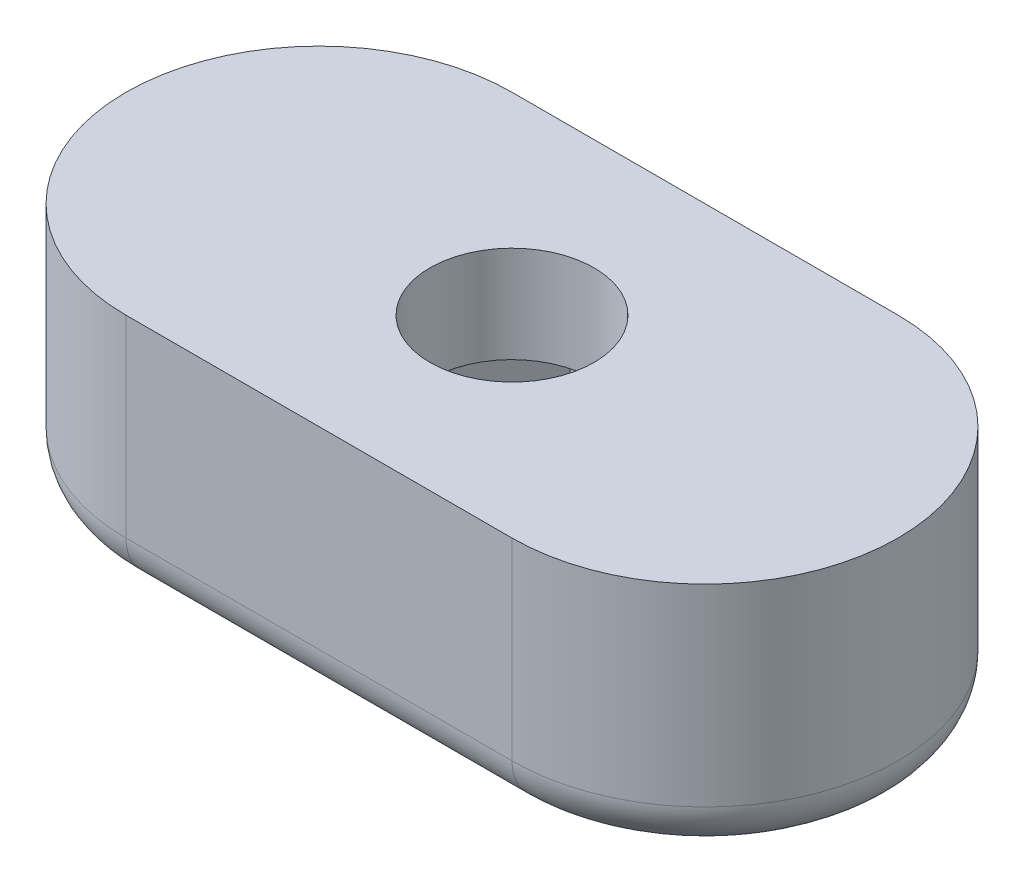
from build123d import *

# Parameters (mm, degrees)
BOSS_EXTRU_1_DEPTH = 5
ESQUISSE2_R        = 1.7
BOSS_EXTRU_2_DEPTH = 2
CONG_1_R           = 1


with BuildPart() as part:
    # Esquisse1 → Boss.-Extru.1 (new body)
    with BuildSketch(Plane(origin=(0, 0, 0), x_dir=(1, 0, 0), z_dir=(0, 1, 0))):
        with BuildLine():
            Line((-4, 4), (4, 4))
            ThreePointArc((4, 4), (8, 0), (4, -4))
            Line((4, -4), (-4, -4))
            ThreePointArc((-4, -4), (-8, 0), (-4, 4))
        make_face()
        Polygon((-1.645448267, 2.85), (1.645448267, 2.85), (3.290896534, 0), (1.645448267, -2.85), (-1.645448267, -2.85), (-3.290896534, 0), align=None, mode=Mode.SUBTRACT)
    extrude(amount=BOSS_EXTRU_1_DEPTH)

    # Esquisse2 → Boss.-Extru.2 (add)
    with BuildSketch(Plane(origin=(0, 5, 0), x_dir=(1, 0, 0), z_dir=(0, 1, 0))):
        with BuildLine():
            Line((-4, -4), (4, -4))
            ThreePointArc((4, -4), (8, 0), (4, 4))
            Line((4, 4), (-4, 4))
            ThreePointArc((-4, 4), (-8, 0), (-4, -4))
        make_face()
        Circle(ESQUISSE2_R, mode=Mode.SUBTRACT)
    extrude(amount=-BOSS_EXTRU_2_DEPTH)

    # Congé1
    cong_1_edges = [part.edges().sort_by_distance(p)[0] for p in [
        (0, 0, -4),
        (8, 0, 0),
        (0, 0, 4),
        (-8, 0, 0),
    ]]
    fillet(cong_1_edges, radius=CONG_1_R)


solid = part.part
